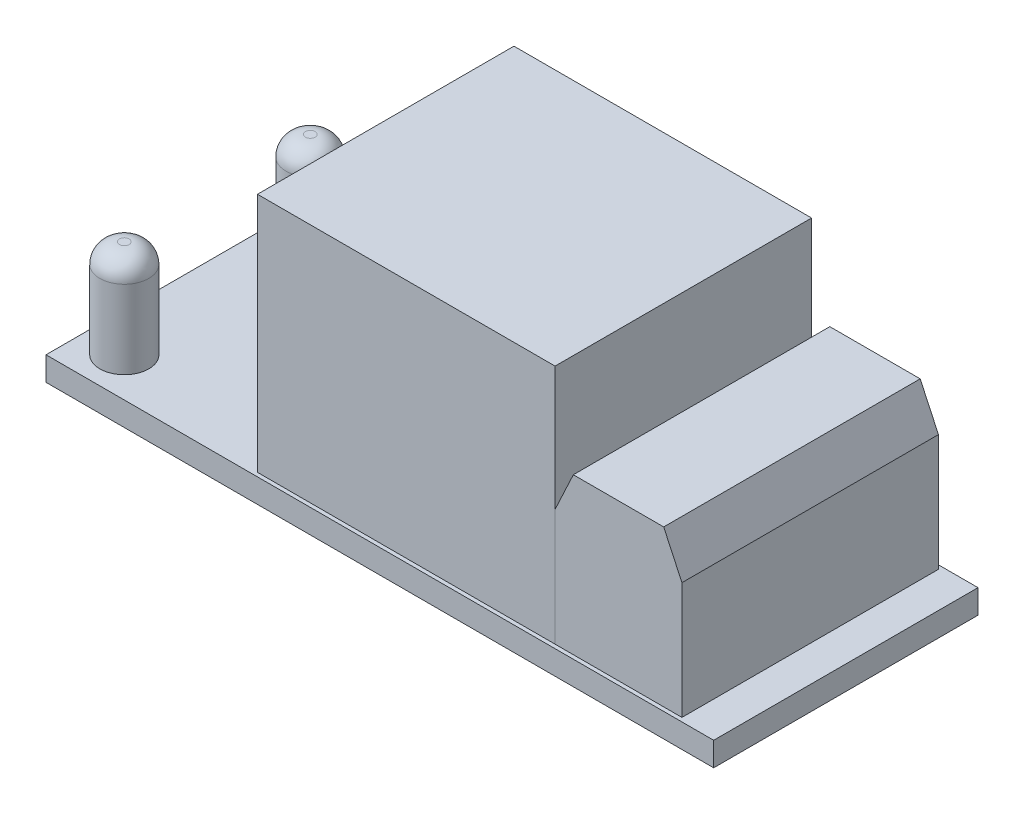
from build123d import *

# Parameters (mm, degrees)
SKETCH1_W             = 43.307
SKETCH1_H             = 17.145
BOSS_EXTRUDE1_DEPTH   = 1.5494
SKETCH2_W             = 19.304
SKETCH2_H             = 16.637
BOSS_EXTRUDE2_DEPTH   = 15.621
SKETCH3_W             = 8.2296
SKETCH3_H             = 16.637
BOSS_EXTRUDE3_DEPTH   = 10.1092
CHAMFER1_SIZE         = 2.54
CHAMFER1_SIZE2        = 1.184421452
CHAMFER1_PART_2_SIZE  = 2.54
CHAMFER1_PART_2_SIZE2 = 1.184421452
SKETCH4_R             = 1.5875
BOSS_EXTRUDE4_DEPTH   = 6.35
FILLET2_R             = 1.27
SKETCH5_R             = 1.5875
BOSS_EXTRUDE5_DEPTH   = 6.35
FILLET1_R             = 1.27


with BuildPart() as part:
    # Sketch1 → Boss-Extrude1 (new body)
    with BuildSketch(Plane(origin=(0, 0, 0), x_dir=(1, 0, 0), z_dir=(0, 1, 0))):
        Rectangle(SKETCH1_W, SKETCH1_H)
    extrude(amount=BOSS_EXTRUDE1_DEPTH)

    # Sketch2 → Boss-Extrude2 (add)
    with BuildSketch(Plane(origin=(0, 1.5494, 0), x_dir=(1, 0, 0), z_dir=(0, 1, 0))):
        with Locations((1.4605, 0)):
            Rectangle(SKETCH2_W, SKETCH2_H)
    extrude(amount=BOSS_EXTRUDE2_DEPTH)

    # Sketch5 → Boss-Extrude5 (add)
    with BuildSketch(Plane(origin=(0, 1.5494, 0), x_dir=(1, 0, 0), z_dir=(0, 1, 0))):
        with Locations((-19.1135, -6.0325)):
            Circle(SKETCH5_R)
    extrude(amount=BOSS_EXTRUDE5_DEPTH)

    # Fillet1
    fillet1_edges = [part.edges().sort_by_distance(p)[0] for p in [
        (-20.701, 7.8994, 6.0325),
    ]]
    fillet(fillet1_edges, radius=FILLET1_R)


with BuildPart() as body_2:
    # Sketch3 → Boss-Extrude3 (new body)
    with BuildSketch(Plane(origin=(0, 1.5494, 0), x_dir=(1, 0, 0), z_dir=(0, 1, 0))):
        with Locations((15.2273, 0)):
            Rectangle(SKETCH3_W, SKETCH3_H)
    extrude(amount=BOSS_EXTRUDE3_DEPTH)

    # Chamfer1
    chamfer1_edges = [body_2.edges().sort_by_distance(p)[0] for p in [
        (19.3421, 11.6586, 0),
    ]]
    chamfer1_side = [body_2.faces().sort_by_distance(p)[0] for p in [
        (19.3421, 6.604, 0),
    ]]
    chamfer(chamfer1_edges, length=CHAMFER1_SIZE, length2=CHAMFER1_SIZE2, reference=chamfer1_side[0])

    # Chamfer1 part 2
    chamfer1_part_2_edges = [body_2.edges().sort_by_distance(p)[0] for p in [
        (11.1125, 11.6586, 0),
    ]]
    chamfer1_part_2_side = [body_2.faces().sort_by_distance(p)[0] for p in [
        (11.1125, 6.604, 0),
    ]]
    chamfer(chamfer1_part_2_edges, length=CHAMFER1_PART_2_SIZE, length2=CHAMFER1_PART_2_SIZE2, reference=chamfer1_part_2_side[0])


with BuildPart() as body_3:
    # Sketch4 → Boss-Extrude4 (new body)
    with BuildSketch(Plane(origin=(0, 1.5494, 0), x_dir=(1, 0, 0), z_dir=(0, 1, 0))):
        with Locations((-19.1135, 6.0325)):
            Circle(SKETCH4_R)
    extrude(amount=BOSS_EXTRUDE4_DEPTH)

    # Fillet2
    fillet2_edges = [body_3.edges().sort_by_distance(p)[0] for p in [
        (-20.701, 7.8994, -6.0325),
    ]]
    fillet(fillet2_edges, radius=FILLET2_R)


solid = Compound([part.part, body_2.part, body_3.part])
